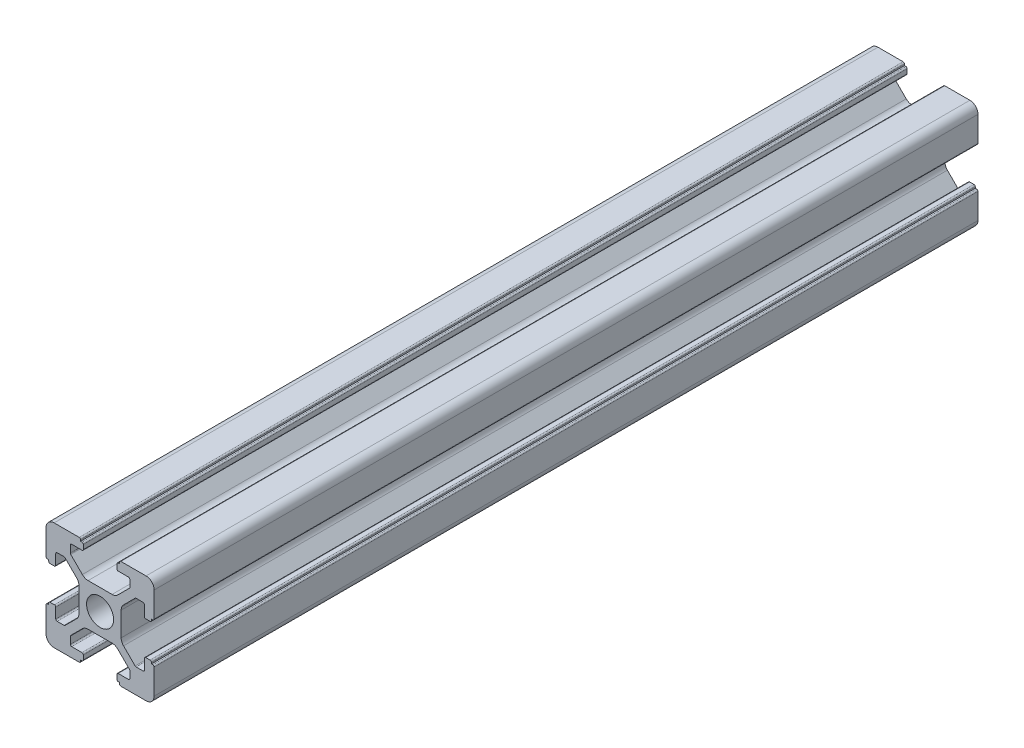
from build123d import *

# Parameters (mm, degrees)
SKETCH_1_R      = 2.5
EXTRUDE_1_DEPTH = 152.4


with BuildPart() as part:
    # 草图1 → 凸台-拉伸1 (new body)
    with BuildSketch(Plane.XY):
        with BuildLine():
            Line((-8.502261885, -10.002261885), (-3.85, -10.002261885))
            ThreePointArc((-3.85, -10.002261885), (-3.673223305, -9.929038581), (-3.6, -9.752261885))
            Line((-3.6, -9.752261885), (-3.6, -9.502261885))
            Line((-3.6, -9.502261885), (-3.35, -9.502261885))
            ThreePointArc((-3.35, -9.502261885), (-3.173223305, -9.429038581), (-3.1, -9.252261885))
            Line((-3.1, -9.252261885), (-3.1, -8.45))
            ThreePointArc((-3.1, -8.45), (-3.173223305, -8.273223305), (-3.35, -8.2))
            Line((-3.35, -8.2), (-5.25, -8.2))
            ThreePointArc((-5.25, -8.2), (-5.426776695, -8.126776695), (-5.5, -7.95))
            Line((-5.5, -7.95), (-5.5, -6.664213562))
            ThreePointArc((-5.5, -6.664213562), (-5.480969883, -6.568542704), (-5.426776695, -6.487436867))
            Line((-5.426776695, -6.487436867), (-3.278679656, -4.339339828))
            ThreePointArc((-3.278679656, -4.339339828), (-2.792044633, -4.014180701), (-2.218019485, -3.9))
            Line((-2.218019485, -3.9), (2.218019485, -3.9))
            ThreePointArc((2.218019485, -3.9), (2.792044633, -4.014180701), (3.278679656, -4.339339828))
            Line((3.278679656, -4.339339828), (5.426776695, -6.487436867))
            ThreePointArc((5.426776695, -6.487436867), (5.480969883, -6.568542704), (5.5, -6.664213562))
            Line((5.5, -6.664213562), (5.5, -7.95))
            ThreePointArc((5.5, -7.95), (5.426776695, -8.126776695), (5.25, -8.2))
            Line((5.25, -8.2), (3.35, -8.2))
            ThreePointArc((3.35, -8.2), (3.173223305, -8.273223305), (3.1, -8.45))
            Line((3.1, -8.45), (3.1, -9.252261885))
            ThreePointArc((3.1, -9.252261885), (3.173223305, -9.429038581), (3.35, -9.502261885))
            Line((3.35, -9.502261885), (3.6, -9.502261885))
            Line((3.6, -9.502261885), (3.6, -9.752261885))
            ThreePointArc((3.6, -9.752261885), (3.673223305, -9.929038581), (3.85, -10.002261885))
            Line((3.85, -10.002261885), (8.502261885, -10.002261885))
            ThreePointArc((8.502261885, -10.002261885), (9.562922057, -9.562922057), (10.002261885, -8.502261885))
            Line((10.002261885, -8.502261885), (10.002261885, -3.85))
            ThreePointArc((10.002261885, -3.85), (9.929038581, -3.673223305), (9.752261885, -3.6))
            Line((9.752261885, -3.6), (9.502261885, -3.6))
            Line((9.502261885, -3.6), (9.502261885, -3.35))
            ThreePointArc((9.502261885, -3.35), (9.429038581, -3.173223305), (9.252261885, -3.1))
            Line((9.252261885, -3.1), (8.45, -3.1))
            ThreePointArc((8.45, -3.1), (8.273223305, -3.173223305), (8.2, -3.35))
            Line((8.2, -3.35), (8.2, -5.25))
            ThreePointArc((8.2, -5.25), (8.126776695, -5.426776695), (7.95, -5.5))
            Line((7.95, -5.5), (6.664213562, -5.5))
            ThreePointArc((6.664213562, -5.5), (6.568542704, -5.480969883), (6.487436867, -5.426776695))
            Line((6.487436867, -5.426776695), (4.339339828, -3.278679656))
            ThreePointArc((4.339339828, -3.278679656), (4.014180701, -2.792044633), (3.9, -2.218019485))
            Line((3.9, -2.218019485), (3.9, 2.218019485))
            ThreePointArc((3.9, 2.218019485), (4.014180701, 2.792044633), (4.339339828, 3.278679656))
            Line((4.339339828, 3.278679656), (6.487436867, 5.426776695))
            ThreePointArc((6.487436867, 5.426776695), (6.568542704, 5.480969883), (6.664213562, 5.5))
            Line((6.664213562, 5.5), (7.95, 5.5))
            ThreePointArc((7.95, 5.5), (8.126776695, 5.426776695), (8.2, 5.25))
            Line((8.2, 5.25), (8.2, 3.35))
            ThreePointArc((8.2, 3.35), (8.273223305, 3.173223305), (8.45, 3.1))
            Line((8.45, 3.1), (9.252261885, 3.1))
            ThreePointArc((9.252261885, 3.1), (9.429038581, 3.173223305), (9.502261885, 3.35))
            Line((9.502261885, 3.35), (9.502261885, 3.6))
            Line((9.502261885, 3.6), (9.752261885, 3.6))
            ThreePointArc((9.752261885, 3.6), (9.929038581, 3.673223305), (10.002261885, 3.85))
            Line((10.002261885, 3.85), (10.002261885, 8.502261885))
            ThreePointArc((10.002261885, 8.502261885), (9.562922057, 9.562922057), (8.502261885, 10.002261885))
            Line((8.502261885, 10.002261885), (3.85, 10.002261885))
            ThreePointArc((3.85, 10.002261885), (3.673223305, 9.929038581), (3.6, 9.752261885))
            Line((3.6, 9.752261885), (3.6, 9.502261885))
            Line((3.6, 9.502261885), (3.35, 9.502261885))
            ThreePointArc((3.35, 9.502261885), (3.173223305, 9.429038581), (3.1, 9.252261885))
            Line((3.1, 9.252261885), (3.1, 8.45))
            ThreePointArc((3.1, 8.45), (3.173223305, 8.273223305), (3.35, 8.2))
            Line((3.35, 8.2), (5.25, 8.2))
            ThreePointArc((5.25, 8.2), (5.426776695, 8.126776695), (5.5, 7.95))
            Line((5.5, 7.95), (5.5, 6.664213562))
            ThreePointArc((5.5, 6.664213562), (5.480969883, 6.568542704), (5.426776695, 6.487436867))
            Line((5.426776695, 6.487436867), (3.278679656, 4.339339828))
            ThreePointArc((3.278679656, 4.339339828), (2.792044633, 4.014180701), (2.218019485, 3.9))
            Line((2.218019485, 3.9), (-2.218019485, 3.9))
            ThreePointArc((-2.218019485, 3.9), (-2.792044633, 4.014180701), (-3.278679656, 4.339339828))
            Line((-3.278679656, 4.339339828), (-5.426776695, 6.487436867))
            ThreePointArc((-5.426776695, 6.487436867), (-5.480969883, 6.568542704), (-5.5, 6.664213562))
            Line((-5.5, 6.664213562), (-5.5, 7.95))
            ThreePointArc((-5.5, 7.95), (-5.426776695, 8.126776695), (-5.25, 8.2))
            Line((-5.25, 8.2), (-3.35, 8.2))
            ThreePointArc((-3.35, 8.2), (-3.173223305, 8.273223305), (-3.1, 8.45))
            Line((-3.1, 8.45), (-3.1, 9.252261885))
            ThreePointArc((-3.1, 9.252261885), (-3.173223305, 9.429038581), (-3.35, 9.502261885))
            Line((-3.35, 9.502261885), (-3.6, 9.502261885))
            Line((-3.6, 9.502261885), (-3.6, 9.752261885))
            ThreePointArc((-3.6, 9.752261885), (-3.673223305, 9.929038581), (-3.85, 10.002261885))
            Line((-3.85, 10.002261885), (-8.502261885, 10.002261885))
            ThreePointArc((-8.502261885, 10.002261885), (-9.562922057, 9.562922057), (-10.002261885, 8.502261885))
            Line((-10.002261885, 8.502261885), (-10.002261885, 3.85))
            ThreePointArc((-10.002261885, 3.85), (-9.929038581, 3.673223305), (-9.752261885, 3.6))
            Line((-9.752261885, 3.6), (-9.502261885, 3.6))
            Line((-9.502261885, 3.6), (-9.502261885, 3.35))
            ThreePointArc((-9.502261885, 3.35), (-9.429038581, 3.173223305), (-9.252261885, 3.1))
            Line((-9.252261885, 3.1), (-8.45, 3.1))
            ThreePointArc((-8.45, 3.1), (-8.273223305, 3.173223305), (-8.2, 3.35))
            Line((-8.2, 3.35), (-8.2, 5.25))
            ThreePointArc((-8.2, 5.25), (-8.126776695, 5.426776695), (-7.95, 5.5))
            Line((-7.95, 5.5), (-6.664213562, 5.5))
            ThreePointArc((-6.664213562, 5.5), (-6.568542704, 5.480969883), (-6.487436867, 5.426776695))
            Line((-6.487436867, 5.426776695), (-4.339339828, 3.278679656))
            ThreePointArc((-4.339339828, 3.278679656), (-4.014180701, 2.792044633), (-3.9, 2.218019485))
            Line((-3.9, 2.218019485), (-3.9, -2.218019485))
            ThreePointArc((-3.9, -2.218019485), (-4.014180701, -2.792044633), (-4.339339828, -3.278679656))
            Line((-4.339339828, -3.278679656), (-6.487436867, -5.426776695))
            ThreePointArc((-6.487436867, -5.426776695), (-6.568542704, -5.480969883), (-6.664213562, -5.5))
            Line((-6.664213562, -5.5), (-7.95, -5.5))
            ThreePointArc((-7.95, -5.5), (-8.126776695, -5.426776695), (-8.2, -5.25))
            Line((-8.2, -5.25), (-8.2, -3.35))
            ThreePointArc((-8.2, -3.35), (-8.273223305, -3.173223305), (-8.45, -3.1))
            Line((-8.45, -3.1), (-9.252261885, -3.1))
            ThreePointArc((-9.252261885, -3.1), (-9.429038581, -3.173223305), (-9.502261885, -3.35))
            Line((-9.502261885, -3.35), (-9.502261885, -3.6))
            Line((-9.502261885, -3.6), (-9.752261885, -3.6))
            ThreePointArc((-9.752261885, -3.6), (-9.929038581, -3.673223305), (-10.002261885, -3.85))
            Line((-10.002261885, -3.85), (-10.002261885, -8.502261885))
            ThreePointArc((-10.002261885, -8.502261885), (-9.562922057, -9.562922057), (-8.502261885, -10.002261885))
        make_face()
        Circle(SKETCH_1_R, mode=Mode.SUBTRACT)
    extrude(amount=EXTRUDE_1_DEPTH)


solid = part.part
